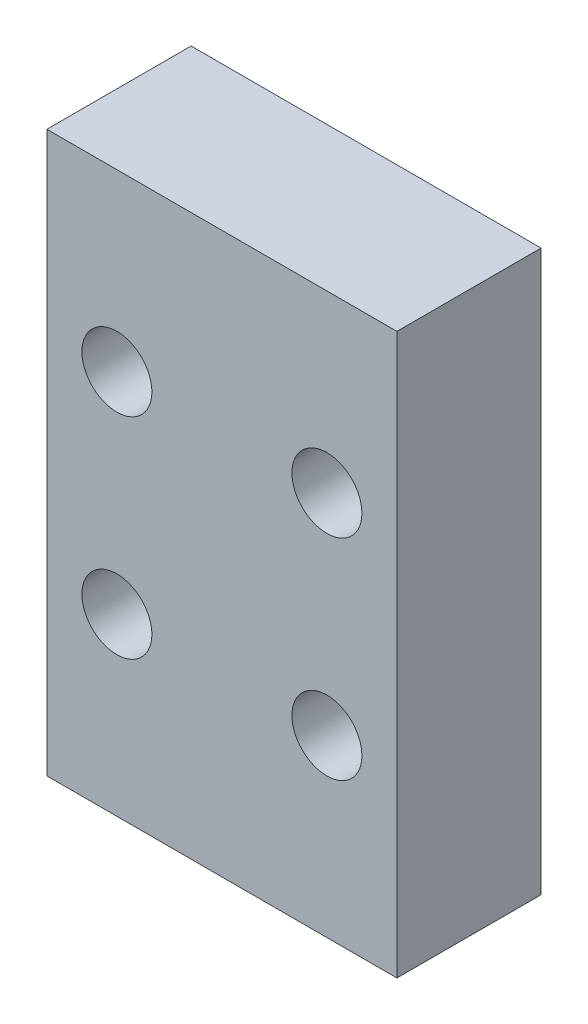
from build123d import *

# Parameters (mm, degrees)
SKETCH1_W           = 31.75
SKETCH1_H           = 50.8
BOSS_EXTRUDE1_DEPTH = 13.081
CUT_EXTRUDE1_REACH  = 15.081
SKETCH2_R           = 3.175


with BuildPart() as part:
    # Sketch1 → Boss-Extrude1 (new body)
    with BuildSketch(Plane.XY):
        with Locations((15.875, 25.4)):
            Rectangle(SKETCH1_W, SKETCH1_H)
    extrude(amount=BOSS_EXTRUDE1_DEPTH)

    # Sketch2 → Cut-Extrude1 (cut, up to next)
    with BuildSketch(Plane.XY.offset(13.081), mode=Mode.PRIVATE) as cut_extrude1_sk1:
        with Locations((25.4, 34.925)):
            Circle(SKETCH2_R)
    cut_extrude1_tool1 = extrude(cut_extrude1_sk1.sketch, amount=-CUT_EXTRUDE1_REACH, mode=Mode.PRIVATE) & part.part
    add(cut_extrude1_tool1.solids().sort_by_distance((25.4, 34.925, 13.081))[0], mode=Mode.SUBTRACT)
    # Sketch2 → Cut-Extrude1 (cut, up to next)
    with BuildSketch(Plane.XY.offset(13.081), mode=Mode.PRIVATE) as cut_extrude1_sk2:
        with Locations((6.35, 34.925)):
            Circle(SKETCH2_R)
    cut_extrude1_tool2 = extrude(cut_extrude1_sk2.sketch, amount=-CUT_EXTRUDE1_REACH, mode=Mode.PRIVATE) & part.part
    add(cut_extrude1_tool2.solids().sort_by_distance((6.35, 34.925, 13.081))[0], mode=Mode.SUBTRACT)
    # Sketch2 → Cut-Extrude1 (cut, up to next)
    with BuildSketch(Plane.XY.offset(13.081), mode=Mode.PRIVATE) as cut_extrude1_sk3:
        with Locations((6.35, 15.875)):
            Circle(SKETCH2_R)
    cut_extrude1_tool3 = extrude(cut_extrude1_sk3.sketch, amount=-CUT_EXTRUDE1_REACH, mode=Mode.PRIVATE) & part.part
    add(cut_extrude1_tool3.solids().sort_by_distance((6.35, 15.875, 13.081))[0], mode=Mode.SUBTRACT)
    # Sketch2 → Cut-Extrude1 (cut, up to next)
    with BuildSketch(Plane.XY.offset(13.081), mode=Mode.PRIVATE) as cut_extrude1_sk4:
        with Locations((25.4, 15.875)):
            Circle(SKETCH2_R)
    cut_extrude1_tool4 = extrude(cut_extrude1_sk4.sketch, amount=-CUT_EXTRUDE1_REACH, mode=Mode.PRIVATE) & part.part
    add(cut_extrude1_tool4.solids().sort_by_distance((25.4, 15.875, 13.081))[0], mode=Mode.SUBTRACT)


solid = part.part
